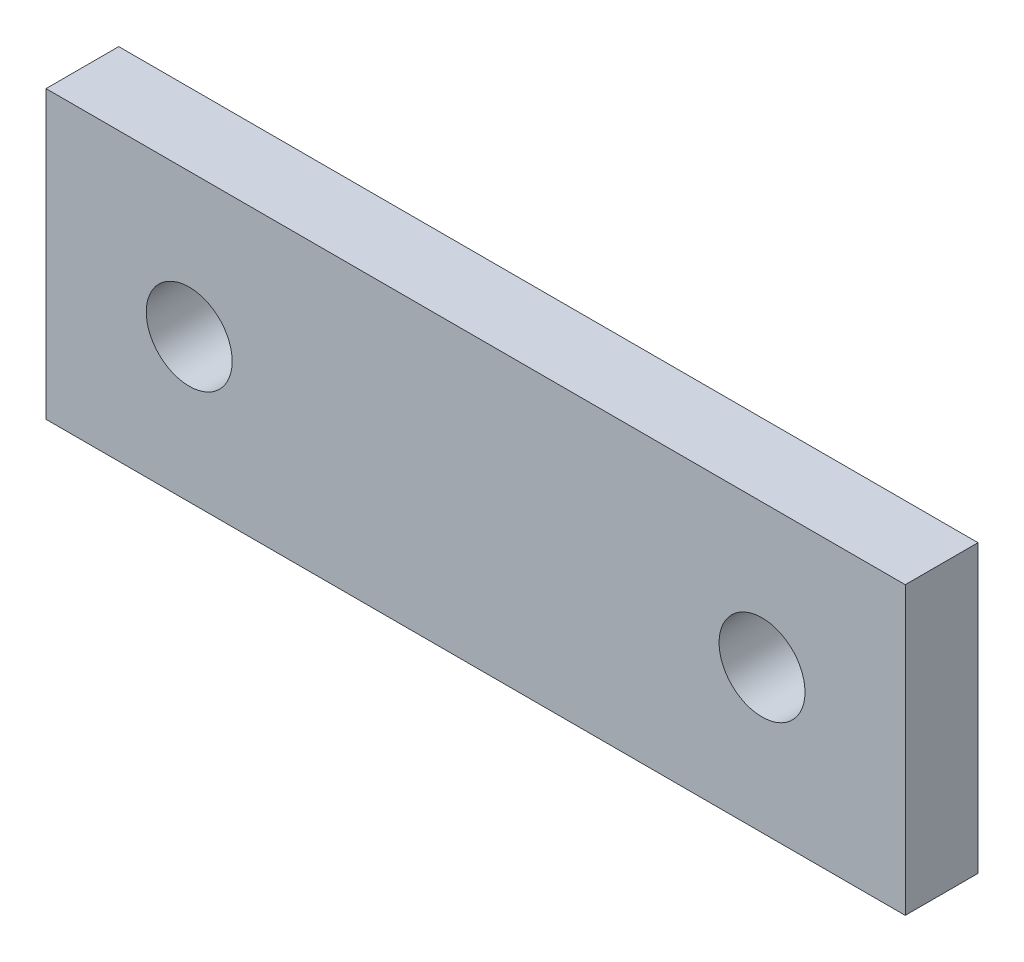
from build123d import *

# Parameters (mm, degrees)
SKETCH1_W           = 30
SKETCH1_H           = 10
SKETCH1_R           = 1.5
BOSS_EXTRUDE1_DEPTH = 2.54


with BuildPart() as part:
    # Sketch1 → Boss-Extrude1 (new body)
    with BuildSketch(Plane.XY):
        with Locations((-16.656164384, 1.35)):
            Rectangle(SKETCH1_W, SKETCH1_H)
        with Locations((-26.656164384, 1.35)):
            Circle(SKETCH1_R, mode=Mode.SUBTRACT)
        with Locations((-6.656164384, 1.35)):
            Circle(SKETCH1_R, mode=Mode.SUBTRACT)
    extrude(amount=BOSS_EXTRUDE1_DEPTH)


solid = part.part
